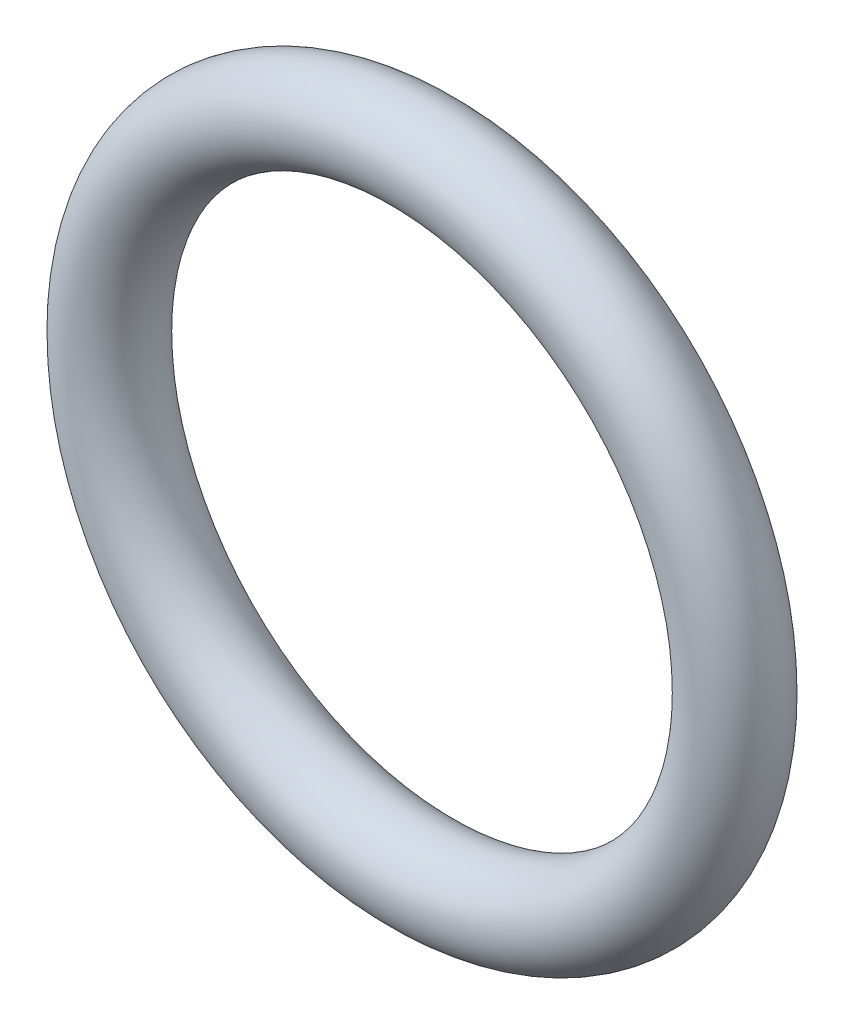
from build123d import *

# Parameters (mm, degrees)
SKETCH1_R = 0.889


with BuildPart() as part:
    # Sketch1 → Revolve1 (revolve)
    with BuildSketch(Plane(origin=(0, 0, 0), x_dir=(0, -1, 0), z_dir=(1, 0, 0))):
        with Locations((6.2992, 0)):
            Circle(SKETCH1_R)
    revolve(axis=Axis((0, 0, 0.889), (0, 0, -1)))


solid = part.part
